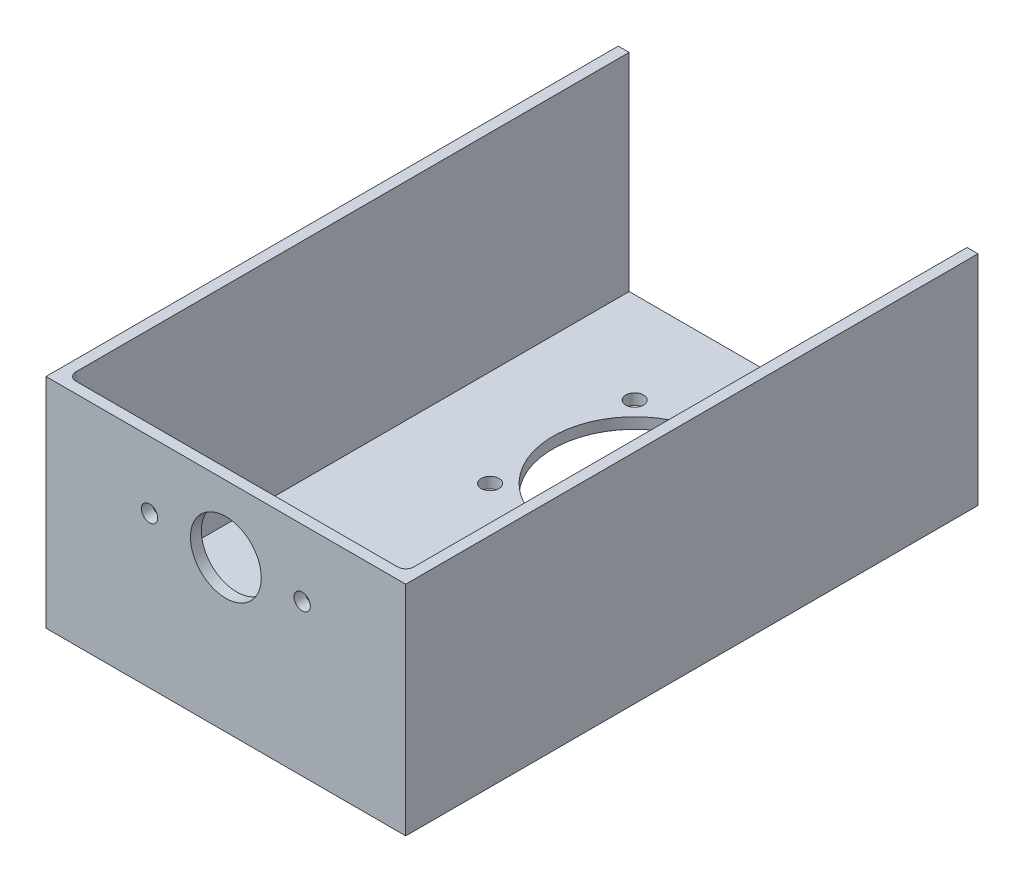
from build123d import *

# Parameters (mm, degrees)
SKETCH_1_W          = 132
SKETCH_1_H          = 80
EXTRUDE_1_DEPTH     = 210
SKETCH_2_W          = 124
SKETCH_2_H          = 206
CUT_EXTRUDE_1_DEPTH = 76
SKETCH_3_R          = 13
SKETCH_3_R_2        = 3
CUT_EXTRUDE_2_DEPTH = 10
SKETCH_4_R          = 3.25
SKETCH_4_R_2        = 30
CUT_EXTRUDE_3_DEPTH = 10
FILLET_1_R          = 3


with BuildPart() as part:
    # 草图1 → 凸台-拉伸1 (new body)
    with BuildSketch(Plane.XY):
        Rectangle(SKETCH_1_W, SKETCH_1_H)
    extrude(amount=-EXTRUDE_1_DEPTH)

    # 草图2 → 切除-拉伸1 (cut)
    with BuildSketch(Plane(origin=(0, 40, 0), x_dir=(1, 0, 0), z_dir=(0, 1, 0))):
        with Locations((0, 107)):
            Rectangle(SKETCH_2_W, SKETCH_2_H)
    extrude(amount=-CUT_EXTRUDE_1_DEPTH, mode=Mode.SUBTRACT)

    # 草图3 → 切除-拉伸2 (cut)
    with BuildSketch(Plane.XY):
        with Locations((0, 15.5)):
            Circle(SKETCH_3_R)
        with Locations((-28, 15.5)):
            Circle(SKETCH_3_R_2)
        with Locations((28, 15.5)):
            Circle(SKETCH_3_R_2)
    extrude(amount=-CUT_EXTRUDE_2_DEPTH, mode=Mode.SUBTRACT)

    # 草图4 → 切除-拉伸3 (cut)
    with BuildSketch(Plane(origin=(0, -36, 0), x_dir=(1, 0, 0), z_dir=(0, 1, 0))):
        with Locations((26.516504294, 176.516504294)):
            Circle(SKETCH_4_R)
        with Locations((26.516504294, 123.483495706)):
            Circle(SKETCH_4_R)
        with Locations((-26.516504294, 123.483495706)):
            Circle(SKETCH_4_R)
        with Locations((-26.516504294, 176.516504294)):
            Circle(SKETCH_4_R)
        with Locations((0, 150)):
            Circle(SKETCH_4_R_2)
    extrude(amount=-CUT_EXTRUDE_3_DEPTH, mode=Mode.SUBTRACT)

    # 圆角1
    fillet_1_edges = [part.edges().sort_by_distance(p)[0] for p in [
        (-62, 2, -4),
        (62, 2, -4),
    ]]
    fillet(fillet_1_edges, radius=FILLET_1_R)


solid = part.part
